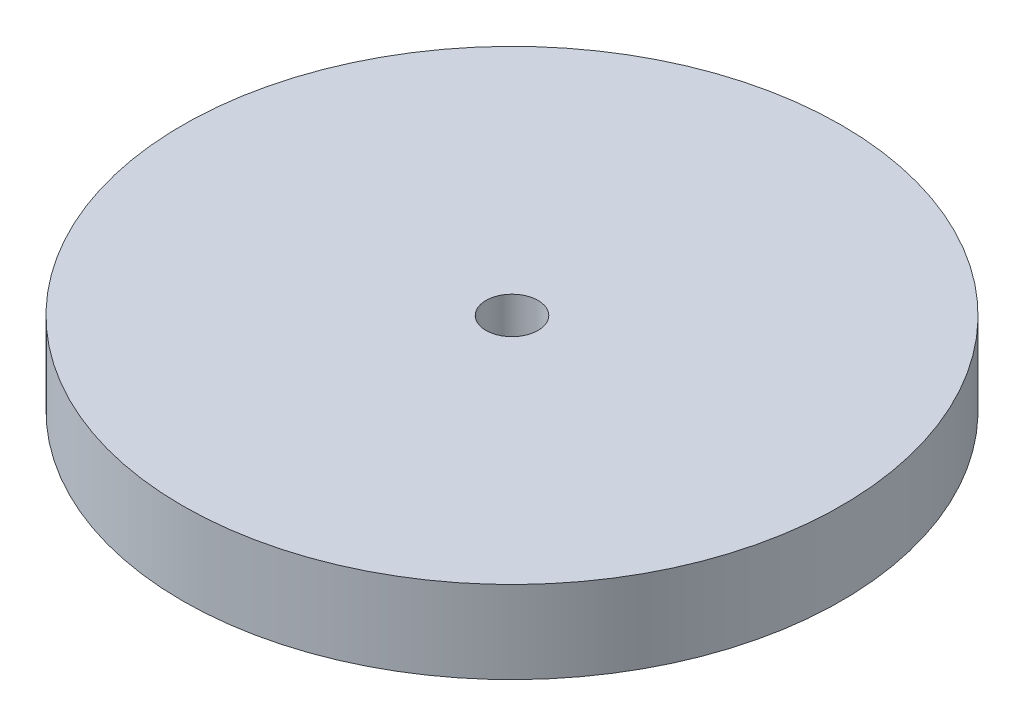
from build123d import *

# Parameters (mm, degrees)
SKETCH1_R           = 25.4
SKETCH1_R_2         = 2.0066
BOSS_EXTRUDE1_DEPTH = 6.35


with BuildPart() as part:
    # Sketch1 → Boss-Extrude1 (new body)
    with BuildSketch(Plane(origin=(0, 0, 0), x_dir=(1, 0, 0), z_dir=(0, 1, 0))):
        Circle(SKETCH1_R)
        Circle(SKETCH1_R_2, mode=Mode.SUBTRACT)
    extrude(amount=BOSS_EXTRUDE1_DEPTH)


solid = part.part
